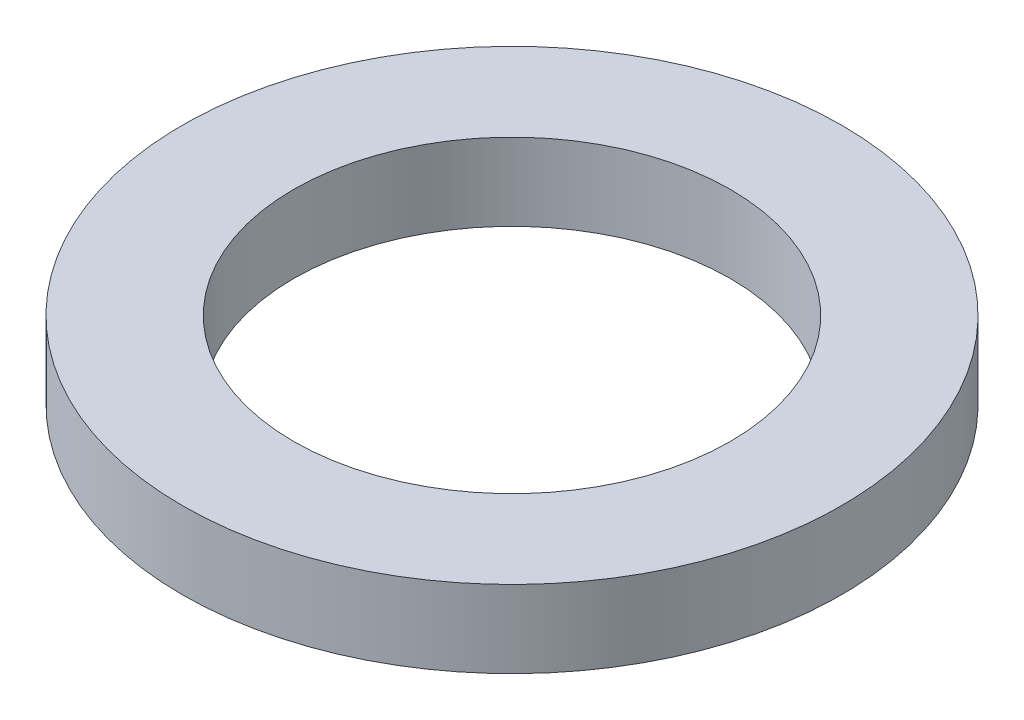
from build123d import *

# Parameters (mm, degrees)
SKETCH1_W = 13.716
SKETCH1_H = 9.525


with BuildPart() as part:
    # Sketch1 → Revolve1 (revolve)
    with BuildSketch(Plane.XY):
        with Locations((33.782, -4.7625)):
            Rectangle(SKETCH1_W, SKETCH1_H)
    revolve(axis=Axis((0, 22.709640493, 0), (0, -1, 0)))


solid = part.part
